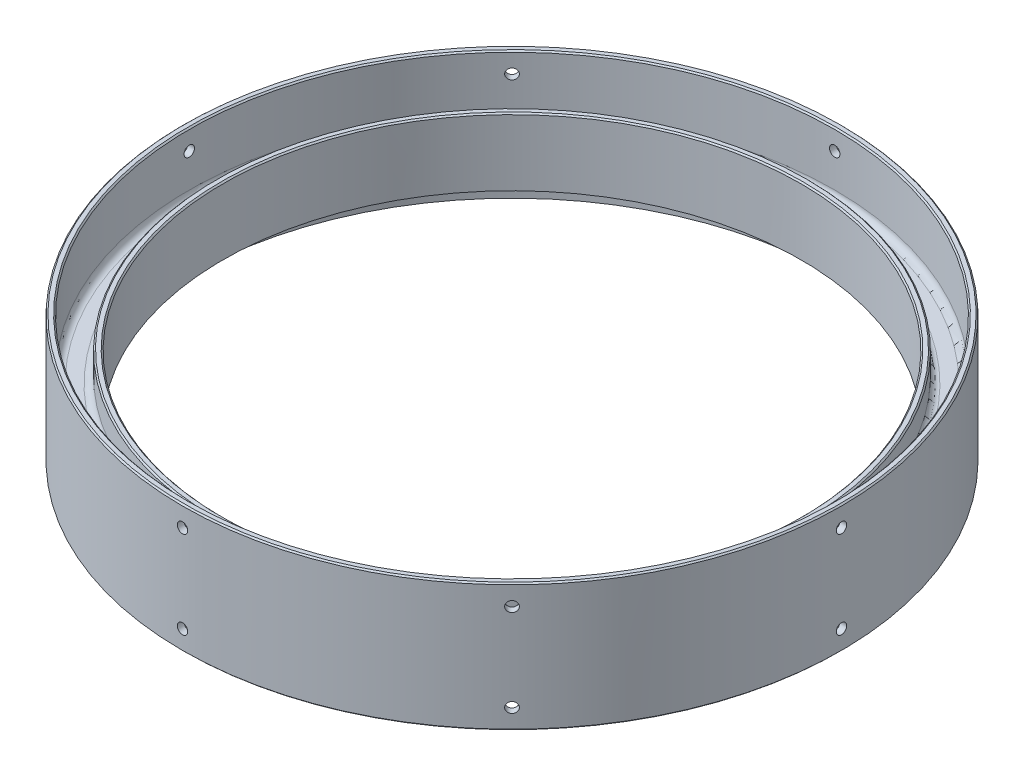
from build123d import *

# Parameters (mm, degrees)
FILLET1_R                             = 3.175
F_10_0_1935_DIAMETER_HOLE1_AT_2_COUNT = 2
F_10_0_1935_DIAMETER_HOLE1_AT_2_PITCH = 41.275
CIRPATTERN7_COUNT                     = 8
CHAMFER1_SIZE                         = 0.635


with BuildPart() as part:
    # Sketch1 → Revolve1 (revolve)
    with BuildSketch(Plane.XY):
        Polygon((136.525, 15.875), (136.525, -15.875), (139.7, -15.875), (139.7, -1.5875), (152.4, -1.5875), (152.4, -30.1625), (155.575, -30.1625), (155.575, 30.1625), (152.4, 30.1625), (152.4, 1.5875), (139.7, 1.5875), (139.7, 15.875), align=None)
    revolve(axis=Axis((0, 44.466373451, 0), (0, -1, 0)))

    # Fillet1
    fillet1_edges = [part.edges().sort_by_distance(p)[0] for p in [
        (-152.4, -1.5875, 0),
        (-139.7, -1.5875, 0),
        (-139.7, 1.5875, 0),
        (-152.4, 1.5875, 0),
    ]]
    fillet(fillet1_edges, radius=FILLET1_R)

    # Sketch9 → #10 (0.1935) Diameter Hole1 (revolve, cut)
    with BuildSketch(Plane(origin=(155.575, 20.6375, 0), x_dir=(0, 0, -1), z_dir=(0, 1, 0))):
        Polygon((0, 0), (0, 26.876584928), (2.45745, 25.4), (2.45745, 0), align=None)
    f_10_0_1935_diameter_hole1 = revolve(axis=Axis((161.925, 20.6375, 0), (-1, 0, 0)), mode=Mode.SUBTRACT)

    # #10 (0.1935) Diameter Hole1 at 2: #10 (0.1935) Diameter Hole1 ×2
    with Locations(*[(0, -i * F_10_0_1935_DIAMETER_HOLE1_AT_2_PITCH, 0) for i in range(1, F_10_0_1935_DIAMETER_HOLE1_AT_2_COUNT)]):
        add(f_10_0_1935_diameter_hole1, mode=Mode.SUBTRACT)

    # CirPattern7: #10 (0.1935) Diameter Hole1 ×8 about axis
    cirpattern7_axis = Axis((0, 30.1625, 0), (0, 1, 0))
    for i in range(1, CIRPATTERN7_COUNT):
        add(f_10_0_1935_diameter_hole1.rotate(cirpattern7_axis, i * 360 / CIRPATTERN7_COUNT), mode=Mode.SUBTRACT)

    # CirPattern7 copy 1 sketch → CirPattern7 copy 1 (revolve, cut)
    with BuildSketch(Plane(origin=(110.008137483, -20.6375, -110.008137483), x_dir=(-0.707106781, 0, -0.707106781), z_dir=(0, 1, 0))):
        Polygon((0, 0), (0, 26.876584928), (2.45745, 25.4), (2.45745, 0), align=None)
    revolve(axis=Axis((114.498265544, -20.6375, -114.498265544), (-0.707106781, 0, 0.707106781)), mode=Mode.SUBTRACT)

    # CirPattern7 copy 2 sketch → CirPattern7 copy 2 (revolve, cut)
    with BuildSketch(Plane(origin=(0, -20.6375, -155.575), x_dir=(-1, 0, 0), z_dir=(0, 1, 0))):
        Polygon((0, 0), (0, 26.876584928), (2.45745, 25.4), (2.45745, 0), align=None)
    revolve(axis=Axis((0, -20.6375, -161.925), (0, 0, 1)), mode=Mode.SUBTRACT)

    # CirPattern7 copy 3 sketch → CirPattern7 copy 3 (revolve, cut)
    with BuildSketch(Plane(origin=(-110.008137483, -20.6375, -110.008137483), x_dir=(-0.707106781, 0, 0.707106781), z_dir=(0, 1, 0))):
        Polygon((0, 0), (0, 26.876584928), (2.45745, 25.4), (2.45745, 0), align=None)
    revolve(axis=Axis((-114.498265544, -20.6375, -114.498265544), (0.707106781, 0, 0.707106781)), mode=Mode.SUBTRACT)

    # CirPattern7 copy 4 sketch → CirPattern7 copy 4 (revolve, cut)
    with BuildSketch(Plane(origin=(-155.575, -20.6375, 0), x_dir=(0, 0, 1), z_dir=(0, 1, 0))):
        Polygon((0, 0), (0, 26.876584928), (2.45745, 25.4), (2.45745, 0), align=None)
    revolve(axis=Axis((-161.925, -20.6375, 0), (1, 0, 0)), mode=Mode.SUBTRACT)

    # CirPattern7 copy 5 sketch → CirPattern7 copy 5 (revolve, cut)
    with BuildSketch(Plane(origin=(-110.008137483, -20.6375, 110.008137483), x_dir=(0.707106781, 0, 0.707106781), z_dir=(0, 1, 0))):
        Polygon((0, 0), (0, 26.876584928), (2.45745, 25.4), (2.45745, 0), align=None)
    revolve(axis=Axis((-114.498265544, -20.6375, 114.498265544), (0.707106781, 0, -0.707106781)), mode=Mode.SUBTRACT)

    # CirPattern7 copy 6 sketch → CirPattern7 copy 6 (revolve, cut)
    with BuildSketch(Plane(origin=(0, -20.6375, 155.575), x_dir=(1, 0, 0), z_dir=(0, 1, 0))):
        Polygon((0, 0), (0, 26.876584928), (2.45745, 25.4), (2.45745, 0), align=None)
    revolve(axis=Axis((0, -20.6375, 161.925), (0, 0, -1)), mode=Mode.SUBTRACT)

    # CirPattern7 copy 7 sketch → CirPattern7 copy 7 (revolve, cut)
    with BuildSketch(Plane(origin=(110.008137483, -20.6375, 110.008137483), x_dir=(0.707106781, 0, -0.707106781), z_dir=(0, 1, 0))):
        Polygon((0, 0), (0, 26.876584928), (2.45745, 25.4), (2.45745, 0), align=None)
    revolve(axis=Axis((114.498265544, -20.6375, 114.498265544), (-0.707106781, 0, -0.707106781)), mode=Mode.SUBTRACT)

    # Chamfer1
    chamfer1_edges = [part.edges().sort_by_distance(p)[0] for p in [
        (-155.575, 30.1625, 0),
        (-155.575, -30.1625, 0),
        (-136.525, 15.875, 0),
        (-139.7, 15.875, 0),
        (-152.4, 30.1625, 0),
    ]]
    chamfer(chamfer1_edges, length=CHAMFER1_SIZE)


solid = part.part
